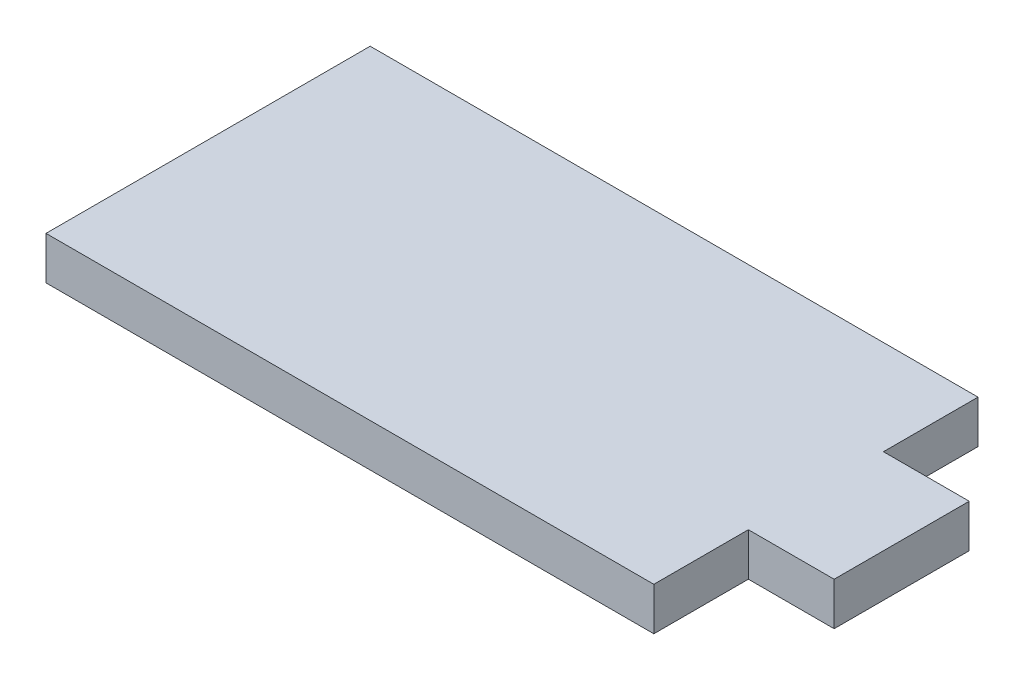
from build123d import *

# Parameters (mm, degrees)
BOSS_EXTRUDE1_DEPTH = 3.175


with BuildPart() as part:
    # Sketch1 → Boss-Extrude1 (new body)
    with BuildSketch(Plane(origin=(0, 0, 0), x_dir=(1, 0, 0), z_dir=(0, 1, 0))):
        Polygon((-22.5, 0), (-22.5, 7), (22.5, 7), (22.5, 0), (28.85, 0), (28.85, -10), (22.5, -10), (22.5, -17), (-22.5, -17), (-22.5, -10), align=None)
    extrude(amount=BOSS_EXTRUDE1_DEPTH)


solid = part.part
